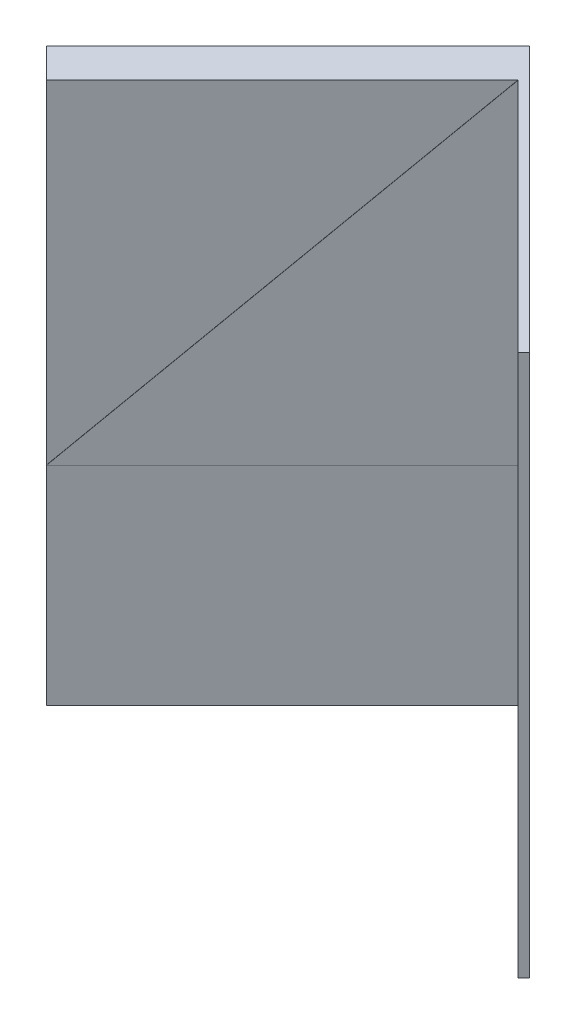
from build123d import *

# Parameters (mm, degrees)
BOSS_EXTRUDE1_DEPTH = 330.2
BOSS_EXTRUDE2_DEPTH = 0.254


with BuildPart() as part:
    # Sketch1 → Boss-Extrude1 (new body)
    with BuildSketch(Plane(origin=(0, 0, 0), x_dir=(1, 0, 0), z_dir=(0, 1, 0))):
        Polygon((0, 0), (-143.684097937, -143.684097937), (-161.644610179, -125.723585695), (-14.368409794, 21.552614691), (147.276200386, -140.091995489), (143.684097937, -143.684097937), align=None)
    extrude(amount=BOSS_EXTRUDE1_DEPTH)

    # Sketch2 → Boss-Extrude2 (add)
    with BuildSketch(Plane(origin=(0, 0, 0), x_dir=(0.707106781, 0, -0.707106781), z_dir=(0.707106781, 0, 0.707106781))):
        Polygon((0, 330.2), (0, 127), (-203.2, 127), align=None)
    extrude(amount=BOSS_EXTRUDE2_DEPTH)


solid = part.part
